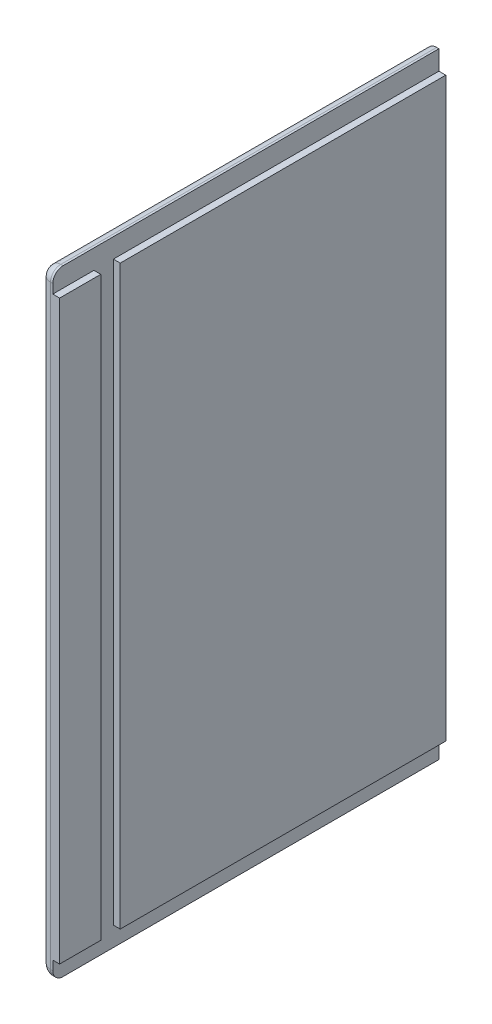
from build123d import *

# Parameters (mm, degrees)
SKETCH1_W           = 357.50000001
SKETCH1_H           = 570
BOSS_EXTRUDE1_DEPTH = 18
SKETCH5_W           = 18
SKETCH5_H           = 557.3
CUT_EXTRUDE3_DEPTH  = 6.35
SKETCH7_W           = 357.50000001
SKETCH7_H           = 18
CUT_EXTRUDE4_DEPTH  = 6.35
FILLET1_R           = 9.525


with BuildPart() as part:
    # Sketch1 → Boss-Extrude1 (new body)
    with BuildSketch(Plane(origin=(0, 0, 0), x_dir=(0, 0, -1), z_dir=(1, 0, 0))):
        with Locations((178.750000005, 285)):
            Rectangle(SKETCH1_W, SKETCH1_H)
    extrude(amount=BOSS_EXTRUDE1_DEPTH)

    # Sketch5 → Cut-Extrude3 (cut)
    with BuildSketch(Plane(origin=(18, 0, 0), x_dir=(0, 0, -1), z_dir=(1, 0, 0))):
        with Locations((47.1, 285)):
            Rectangle(SKETCH5_W, SKETCH5_H)
    extrude(amount=-CUT_EXTRUDE3_DEPTH, mode=Mode.SUBTRACT)

    # Sketch7 → Cut-Extrude4 (cut)
    with BuildSketch(Plane(origin=(18, 0, 0), x_dir=(0, 0, -1), z_dir=(1, 0, 0))):
        with Locations((178.750000005, 9)):
            Rectangle(SKETCH7_W, SKETCH7_H)
        with Locations((178.750000005, 561)):
            Rectangle(SKETCH7_W, SKETCH7_H)
    extrude(amount=-CUT_EXTRUDE4_DEPTH, mode=Mode.SUBTRACT)

    # Fillet1
    fillet1_edges = [part.edges().sort_by_distance(p)[0] for p in [
        (5.825, 0, 0),
        (0, 570, -178.750000005),
        (0, 0, -178.750000005),
        (5.825, 570, 0),
        (0, 285, 0),
    ]]
    fillet(fillet1_edges, radius=FILLET1_R)


solid = part.part
